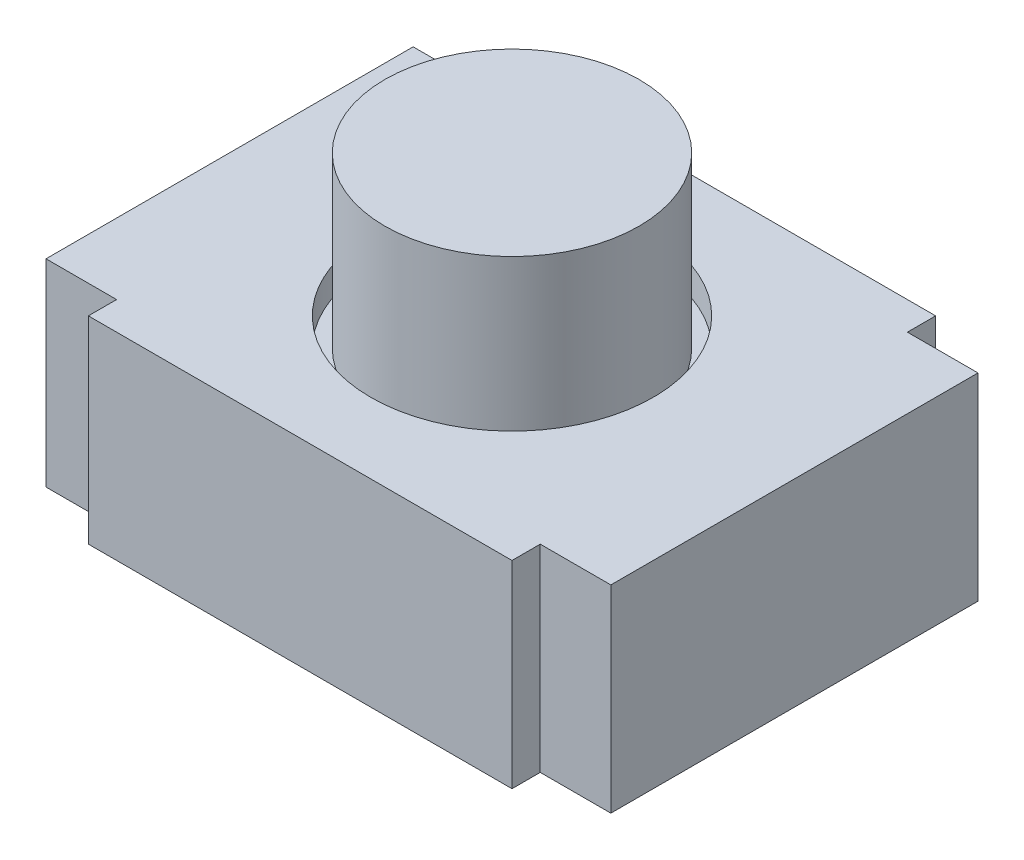
from build123d import *

# Parameters (mm, degrees)
SKETCH1_W           = 4
SKETCH1_H           = 2.6
BOSS_EXTRUDE1_DEPTH = 1.2
BOSS_EXTRUDE2_DEPTH = 0.2
SKETCH3_W           = 3
SKETCH3_H           = 0.2
BOSS_EXTRUDE3_DEPTH = 1.2
SKETCH4_R           = 1
CUT_EXTRUDE1_DEPTH  = 0.2
SKETCH5_R           = 0.9
BOSS_EXTRUDE4_DEPTH = 1.2


with BuildPart() as part:
    # Sketch1 → Boss-Extrude1 (new body)
    with BuildSketch(Plane(origin=(0, 0, 0), x_dir=(1, 0, 0), z_dir=(0, 1, 0))):
        Rectangle(SKETCH1_W, SKETCH1_H)
    extrude(amount=-BOSS_EXTRUDE1_DEPTH)



with BuildPart() as body_2:
    # Sketch2 → Boss-Extrude2 (new body)
    with BuildSketch(Plane(origin=(0, 0, 0), x_dir=(1, 0, 0), z_dir=(0, 1, 0))):
        Polygon((-1.5, 1.5), (1.5, 1.5), (1.5, 1.3), (2, 1.3), (2, -1.3), (1.5, -1.3), (1.5, -1.5), (-1.5, -1.5), (-1.5, -1.3), (-2, -1.3), (-2, 1.3), (-1.5, 1.3), align=None)
    extrude(amount=BOSS_EXTRUDE2_DEPTH)

    # Sketch3 → Boss-Extrude3 (add)
    with BuildSketch(Plane(origin=(0, 0, 0), x_dir=(-1, 0, 0), z_dir=(0, -1, 0))):
        with Locations((0, -1.4)):
            Rectangle(SKETCH3_W, SKETCH3_H)
        with Locations((0, 1.4)):
            Rectangle(SKETCH3_W, SKETCH3_H)
    extrude(amount=BOSS_EXTRUDE3_DEPTH)

    # Sketch4 → Cut-Extrude1 (cut)
    with BuildSketch(Plane(origin=(0, 0.2, 0), x_dir=(1, 0, 0), z_dir=(0, 1, 0))):
        with Locations(Location((0, 0, 0), (0, 0, 270))):
            Circle(SKETCH4_R)
    extrude(amount=-CUT_EXTRUDE1_DEPTH, mode=Mode.SUBTRACT)


with BuildPart() as part_1:
    add(part.part)

    add(body_2.part)  # Boss-Extrude4 merges body 2
    # Sketch5 → Boss-Extrude4 (add)
    with BuildSketch(Plane(origin=(0, 0, 0), x_dir=(1, 0, 0), z_dir=(0, 1, 0))):
        with Locations(Location((0, 0, 0), (0, 0, 270))):
            Circle(SKETCH5_R)
    extrude(amount=BOSS_EXTRUDE4_DEPTH)


solid = part_1.part
